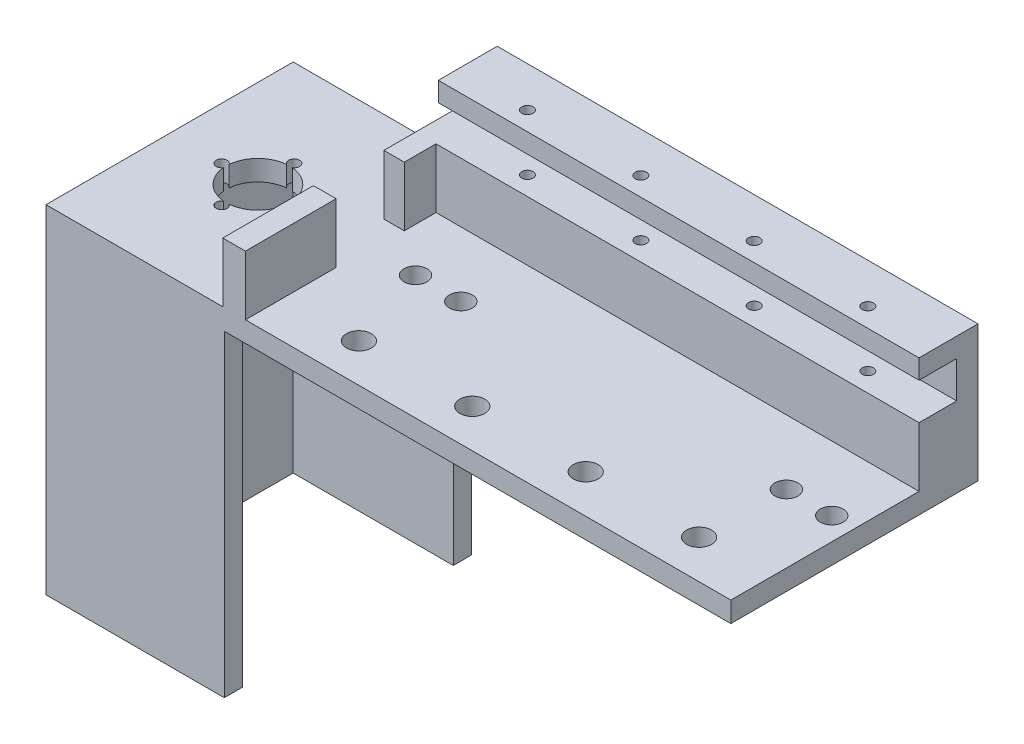
from build123d import *

# Parameters (mm, degrees)
SKETCH4_W                  = 106
SKETCH4_H                  = 30
BOSS_EXTRUDE2_DEPTH        = 13
SKETCH25_W                 = 106
SKETCH25_H                 = 8.1
CUT_EXTRUDE3_DEPTH         = 1
CUT_EXTRUDE3_DEPTH_BACK    = 8.3
M3X0_5_TAPPED_HOLE1_D      = 2.5
SKETCH28_W                 = 106
SKETCH28_H                 = 4.5
BOSS_EXTRUDE3_DEPTH        = 41.5
SKETCH32_W                 = 41.5
SKETCH32_H                 = 4.5
BOSS_EXTRUDE10_DEPTH       = 5
SKETCH33_W                 = 13
SKETCH33_H                 = 17.621445937
BOSS_EXTRUDE12_DEPTH       = 5
SKETCH34_W                 = 4.498886861
SKETCH34_H                 = 13.121445937
BOSS_EXTRUDE13_DEPTH       = 7
SKETCH35_W                 = 54.5
SKETCH35_H                 = 4.5
BOSS_EXTRUDE14_DEPTH       = 40
SKETCH36_W                 = 5
SKETCH36_H                 = 20
BOSS_EXTRUDE15_DEPTH       = 13.12
F_8_0_199_DIAMETER_HOLE1_D = 5.0546
SKETCH39_R                 = 7
CUT_EXTRUDE4_DEPTH         = 10
M2_CLEARANCE_HOLE1_D       = 2.4
M5_CLEARANCE_HOLE1_D       = 5.5
SKETCH43_W                 = 35.304815243
SKETCH43_H                 = 4
BOSS_EXTRUDE16_DEPTH       = 70


with BuildPart() as part:
    # Sketch4 → Boss-Extrude2 (new body)
    with BuildSketch(Plane.XY):
        with Locations((-36.891047602, -35.322762913)):
            Rectangle(SKETCH4_W, SKETCH4_H)
    extrude(amount=-BOSS_EXTRUDE2_DEPTH)

    # Sketch25 → Cut-Extrude3 (cut, two sides)
    with BuildSketch(Plane.XY) as cut_extrude3_sk:
        with Locations((-36.891047602, -28.651316976)):
            Rectangle(SKETCH25_W, SKETCH25_H)
    extrude(amount=CUT_EXTRUDE3_DEPTH, mode=Mode.SUBTRACT)
    extrude(cut_extrude3_sk.sketch, amount=-CUT_EXTRUDE3_DEPTH_BACK, mode=Mode.SUBTRACT)

    # M3x0.5 Tapped Hole1 (through all)
    with Locations(Plane(origin=(-74.390985602, -20.322762913, -4.15), x_dir=(0, 0, 1), z_dir=(0, 1, 0))):
        with Locations((0, 0), (0, 25), (-0.055677319, 74.999938), (0, 50)):
            Hole(M3X0_5_TAPPED_HOLE1_D / 2)

    # Sketch28 → Boss-Extrude3 (add)
    with BuildSketch(Plane.XY):
        with Locations((-36.891047602, -48.072762913)):
            Rectangle(SKETCH28_W, SKETCH28_H)
    extrude(amount=BOSS_EXTRUDE3_DEPTH)

    # Sketch32 → Boss-Extrude10 (add)
    with BuildSketch(Plane.ZY.offset(89.891047602)):
        with Locations((20.75, -48.072762913)):
            Rectangle(SKETCH32_W, SKETCH32_H)
    extrude(amount=BOSS_EXTRUDE10_DEPTH)

    # Sketch33 → Boss-Extrude12 (add)
    with BuildSketch(Plane.ZY.offset(89.891047602)):
        with Locations((-6.5, -41.512039945)):
            Rectangle(SKETCH33_W, SKETCH33_H)
    extrude(amount=BOSS_EXTRUDE12_DEPTH)

    # Sketch34 → Boss-Extrude13 (add)
    with BuildSketch(Plane.XY):
        with Locations((-92.641604172, -39.262039945)):
            Rectangle(SKETCH34_W, SKETCH34_H)
    extrude(amount=BOSS_EXTRUDE13_DEPTH)

    # Sketch35 → Boss-Extrude14 (add)
    with BuildSketch(Plane.ZY.offset(94.891047602)):
        with Locations((14.25, -48.072762913)):
            Rectangle(SKETCH35_W, SKETCH35_H)
    extrude(amount=BOSS_EXTRUDE14_DEPTH)

    # Sketch36 → Boss-Extrude15 (add)
    with BuildSketch(Plane(origin=(0, -45.822762913, 0), x_dir=(1, 0, 0), z_dir=(0, 1, 0))):
        with Locations((-93.41812931, -31.5)):
            Rectangle(SKETCH36_W, SKETCH36_H)
    extrude(amount=BOSS_EXTRUDE15_DEPTH)

    # #8 (0.199) Diameter Hole1 (through all)
    with Locations(Plane(origin=(-80.669073904, -45.822762913, 14.25), x_dir=(0, 0, 1), z_dir=(0, 1, 0))):
        with Locations((0, 0), (0, 91.778026302), (0, 81.778026302), (0, 10)):
            Hole(F_8_0_199_DIAMETER_HOLE1_D / 2)

    # Sketch39 → Cut-Extrude4 (cut)
    with BuildSketch(Plane(origin=(0, -45.822762913, 0), x_dir=(1, 0, 0), z_dir=(0, 1, 0))):
        with Locations((-115.41812931, -14.25)):
            Circle(SKETCH39_R)
    extrude(amount=-CUT_EXTRUDE4_DEPTH, mode=Mode.SUBTRACT)

    # M2 Clearance Hole1 (through all)
    with Locations(Plane(origin=(-107.41812931, -45.822762913, 14.25), x_dir=(0, 0, 1), z_dir=(0, 1, 0))):
        with Locations((0, 0), (8.000007036, -8.002918292), (-7.999992964, -8.002918292), (0, -16)):
            Hole(M2_CLEARANCE_HOLE1_D / 2)

    # M5 Clearance Hole1 (through all)
    with Locations(Plane(origin=(0.608952398, -50.322762913, 33), x_dir=(0, 0, -1), z_dir=(0, -1, 0))):
        with Locations((0, 0), (0, -25), (0, -50), (0, -75)):
            Hole(M5_CLEARANCE_HOLE1_D / 2)

    # Sketch43 → Boss-Extrude16 (add)
    with BuildSketch(Plane(origin=(0, -50.322762913, 0), x_dir=(-1, 0, 0), z_dir=(0, -1, 0))):
        Polygon((95.586232359, -37.5), (95.586232359, -41.5), (134.891047602, -41.5), (134.891047602, -37.5), (130.891047602, -37.5), align=None)
        Polygon((130.891047602, -37.5), (134.891047602, -37.5), (134.891047602, 13), (130.891047602, 13), (130.891047602, 9), align=None)
        with Locations((113.238639981, 11)):
            Rectangle(SKETCH43_W, SKETCH43_H)
    extrude(amount=BOSS_EXTRUDE16_DEPTH)


solid = part.part
